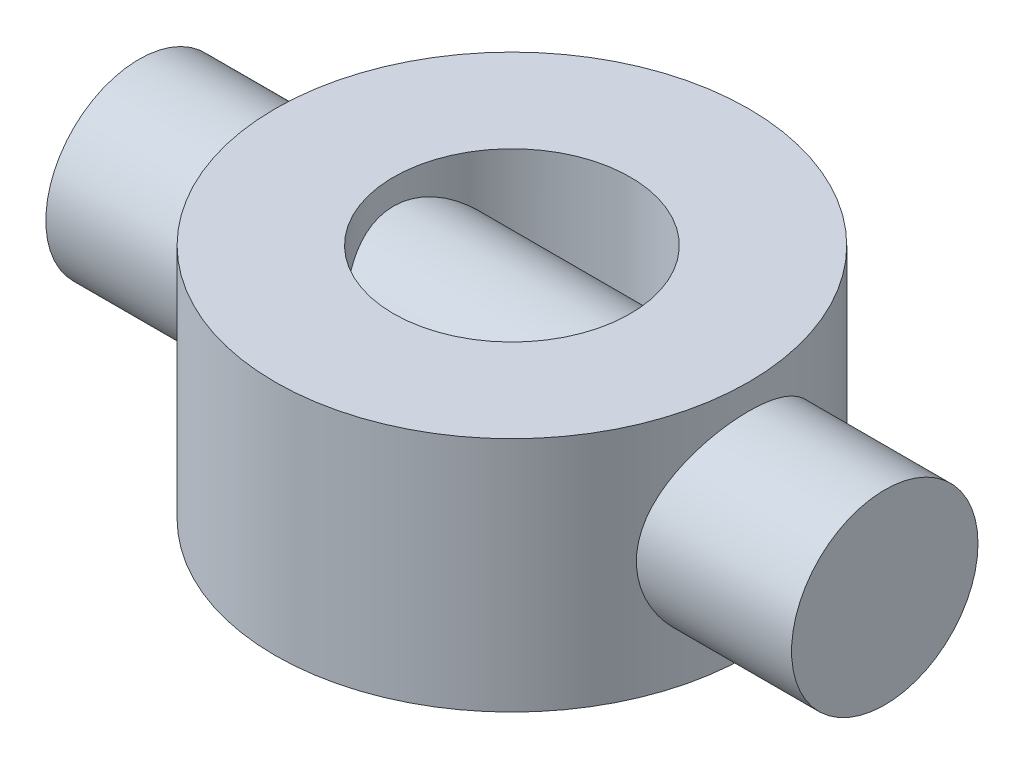
from build123d import *

# Parameters (mm, degrees)
BOSS_EXTRUDE1_DEPTH      = 40
BOSS_EXTRUDE1_DEPTH_BACK = 40
SKETCH2_R                = 10
BOSS_EXTRUDE2_DEPTH      = 12.7
BOSS_EXTRUDE2_DEPTH_BACK = 12.7
SKETCH1_R                = 25.4
SKETCH1_R_2              = 12.7


with BuildPart() as part:
    # Sketch2 → Boss-Extrude1 (new, two sides: drawn at the far end of the back side and taken through both)
    with BuildSketch(Plane(origin=(0, 0, 0), x_dir=(0, 0, -1), z_dir=(1, 0, 0)).offset(-BOSS_EXTRUDE1_DEPTH_BACK)):
        Circle(SKETCH2_R)
    extrude(amount=BOSS_EXTRUDE1_DEPTH + BOSS_EXTRUDE1_DEPTH_BACK)

    # Sketch1 → Boss-Extrude2 (add, two sides: drawn at the far end of the back side and taken through both)
    with BuildSketch(Plane(origin=(0, 0, 0), x_dir=(1, 0, 0), z_dir=(0, 1, 0)).offset(-BOSS_EXTRUDE2_DEPTH_BACK)):
        Circle(SKETCH1_R)
        Circle(SKETCH1_R_2, mode=Mode.SUBTRACT)
    extrude(amount=BOSS_EXTRUDE2_DEPTH + BOSS_EXTRUDE2_DEPTH_BACK)


solid = part.part
